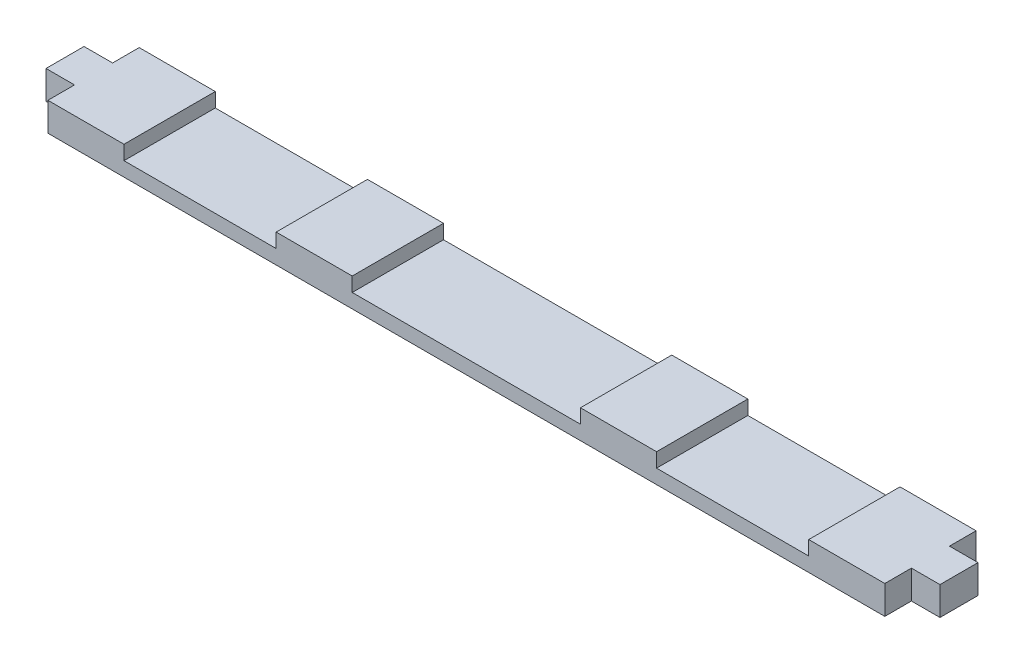
from build123d import *

# Parameters (mm, degrees)
SKETCH1_W           = 279.4
SKETCH1_H           = 30.48
BOSS_EXTRUDE1_DEPTH = 9.525
SKETCH2_W           = 12.7
SKETCH2_H           = 9.525
BOSS_EXTRUDE2_DEPTH = 9.525
SKETCH4_W           = 76.2
SKETCH4_H           = 30.48
SKETCH4_W_2         = 50.8
CUT_EXTRUDE1_DEPTH  = 4.7625


with BuildPart() as part:
    # Sketch1 → Boss-Extrude1 (new body)
    with BuildSketch(Plane(origin=(0, 0, 0), x_dir=(1, 0, 0), z_dir=(0, 1, 0))):
        Rectangle(SKETCH1_W, SKETCH1_H)
    extrude(amount=BOSS_EXTRUDE1_DEPTH)

    # Sketch2 → Boss-Extrude2 (add)
    with BuildSketch(Plane(origin=(139.7, 0, 0), x_dir=(0, 0, -1), z_dir=(1, 0, 0))):
        with Locations((0, 4.7625)):
            Rectangle(SKETCH2_W, SKETCH2_H)
    boss_extrude2 = extrude(amount=BOSS_EXTRUDE2_DEPTH)

    # Mirror1: Boss-Extrude2 across plane
    add(boss_extrude2.mirror(Plane(origin=(0, 0, 0), x_dir=(0, 0, 1), z_dir=(1, 0, 0))))

    # Sketch4 → Cut-Extrude1 (cut)
    with BuildSketch(Plane(origin=(0, 9.525, 0), x_dir=(1, 0, 0), z_dir=(0, 1, 0))):
        Rectangle(SKETCH4_W, SKETCH4_H)
        with Locations((88.9, 0)):
            Rectangle(SKETCH4_W_2, SKETCH4_H)
        with Locations((-88.9, 0)):
            Rectangle(SKETCH4_W_2, SKETCH4_H)
    extrude(amount=-CUT_EXTRUDE1_DEPTH, mode=Mode.SUBTRACT)


solid = part.part
